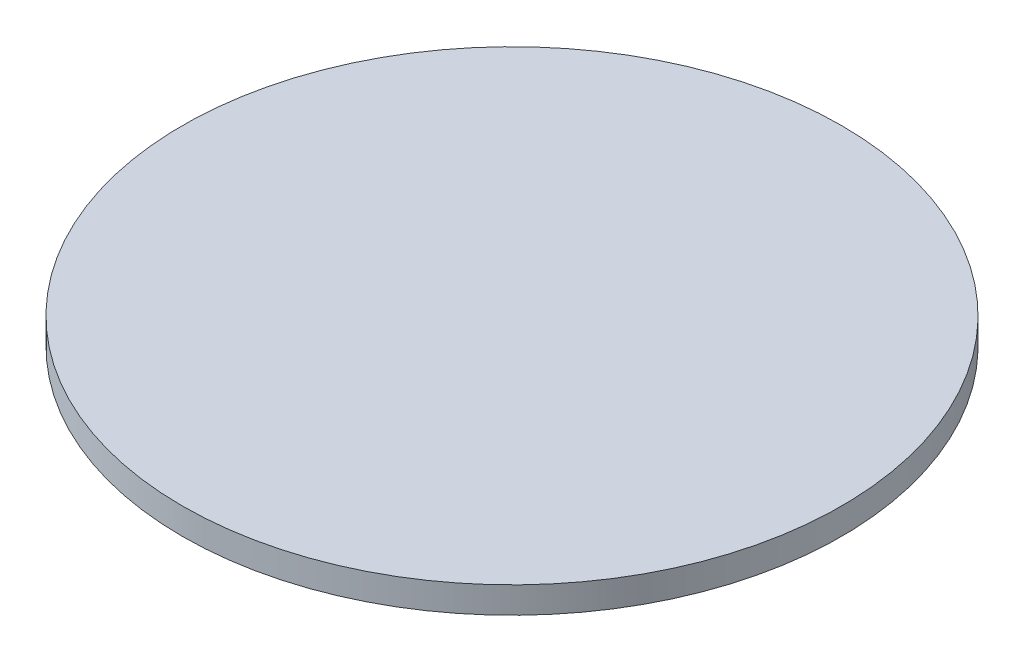
from build123d import *

# Parameters (mm, degrees)
SKETCH_1_R      = 25
EXTRUDE_1_DEPTH = 2


with BuildPart() as part:
    # 草图1 → 凸台-拉伸1 (new body)
    with BuildSketch(Plane(origin=(0, 0, 0), x_dir=(1, 0, 0), z_dir=(0, 1, 0))):
        with Locations(Location((0, 0, 0), (0, 0, 270))):  # turned: the seam where the file's is
            Circle(SKETCH_1_R)
    extrude(amount=EXTRUDE_1_DEPTH)


solid = part.part
